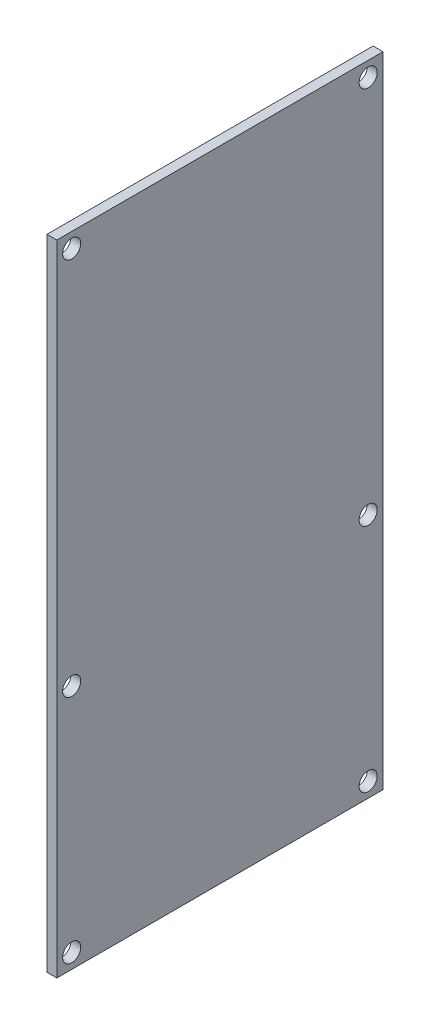
from build123d import *

# Parameters (mm, degrees)
SKETCH1_W           = 99
SKETCH1_H           = 194
BOSS_EXTRUDE1_DEPTH = 3
SKETCH2_R           = 2.75
CUT_EXTRUDE1_DEPTH  = 4


with BuildPart() as part:
    # Sketch1 → Boss-Extrude1 (new body)
    with BuildSketch(Plane(origin=(45.01171607, 0, 0), x_dir=(0, 0, -1), z_dir=(1, 0, 0))):
        with Locations((16.230657269, 7.5)):
            Rectangle(SKETCH1_W, SKETCH1_H)
    extrude(amount=BOSS_EXTRUDE1_DEPTH)

    # Sketch2 → Cut-Extrude1 (cut, through all)
    with BuildSketch(Plane(origin=(48.01171607, 0, 0), x_dir=(0, 0, -1), z_dir=(1, 0, 0))):
        with Locations((-28.769342731, 100)):
            Circle(SKETCH2_R)
        with Locations((61.230657269, 100)):
            Circle(SKETCH2_R)
        with Locations((-28.769342731, -85)):
            Circle(SKETCH2_R)
        with Locations((61.230657269, -85)):
            Circle(SKETCH2_R)
        with Locations((-28.769342731, -15)):
            Circle(SKETCH2_R)
        with Locations((61.230657269, -15)):
            Circle(SKETCH2_R)
    extrude(amount=-CUT_EXTRUDE1_DEPTH, mode=Mode.SUBTRACT)


solid = part.part
